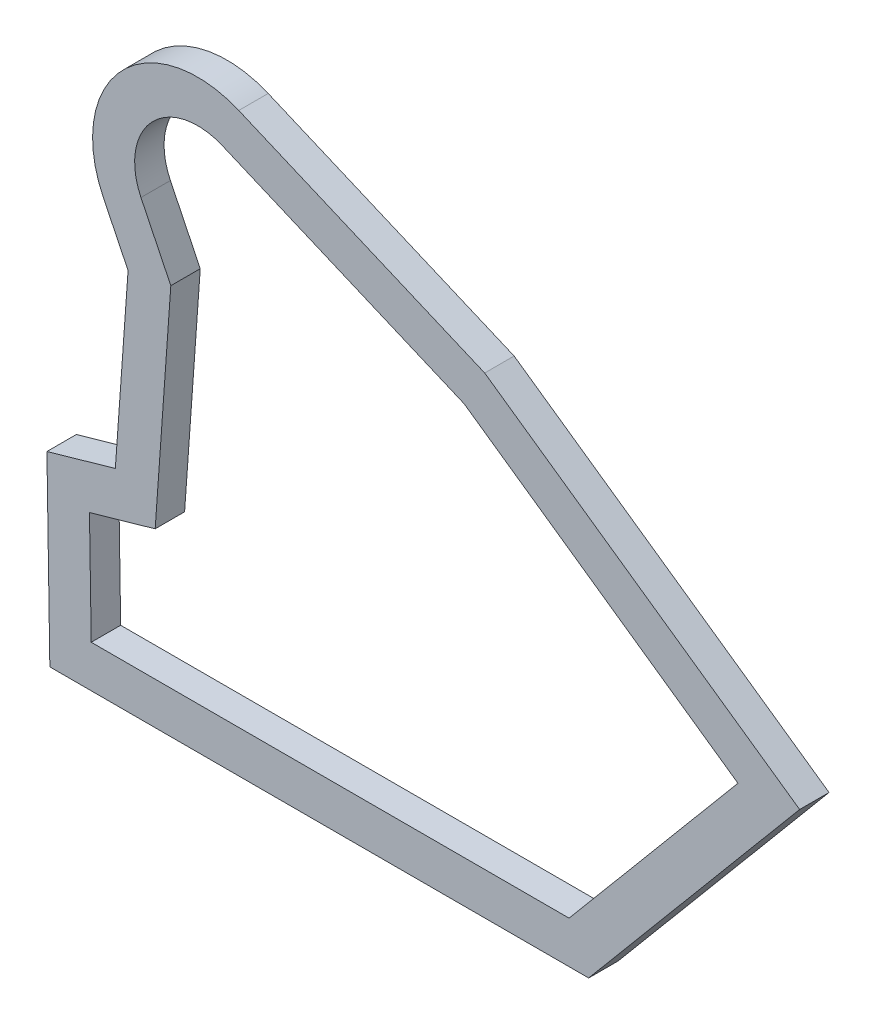
from build123d import *

# Parameters (mm, degrees)
BOSS_EXTRUDE1_DEPTH = 2.8


with BuildPart() as part:
    # Sketch1 → Boss-Extrude1 (new body)
    with BuildSketch(Plane.XY):
        with BuildLine():
            Line((22.037686993, 65.84113938), (45.437304164, 55.908591182))
            Line((45.437304164, 55.908591182), (75.406514927, 34.923923891))
            Line((75.406514927, 34.923923891), (55.331959214, 11))
            Line((55.331959214, 11), (4.062529555, 11))
            Line((4.062529555, 11), (3.78501031, 28.61298402))
            Line((3.78501031, 28.61298402), (10.294447393, 30.467578469))
            Line((10.294447393, 30.467578469), (11.506283895, 47.384777536))
            Line((11.506283895, 47.384777536), (9.135004308, 52.267647945))
            ThreePointArc((9.135004308, 52.267647945), (10.882479022, 63.525792844), (22.037686993, 65.84113938))
        make_face()
        with BuildLine():
            Line((43.487383815, 52.390841754), (69.536418824, 34.151111078))
            Line((69.536418824, 34.151111078), (53.466728581, 15))
            Line((53.466728581, 15), (8, 15))
            Line((8, 15), (7.832869461, 25.60707524))
            Line((7.832869461, 25.60707524), (14.08410383, 27.388105521))
            Line((14.08410383, 27.388105521), (15.572640754, 48.168033695))
            Line((15.572640754, 48.168033695), (12.733152868, 54.015025105))
            ThreePointArc((12.733152868, 54.015025105), (13.781637696, 60.769912045), (20.474762479, 62.159119966))
            Line((20.474762479, 62.159119966), (43.487383815, 52.390841754))
        make_face(mode=Mode.SUBTRACT)
    extrude(amount=BOSS_EXTRUDE1_DEPTH)


solid = part.part
